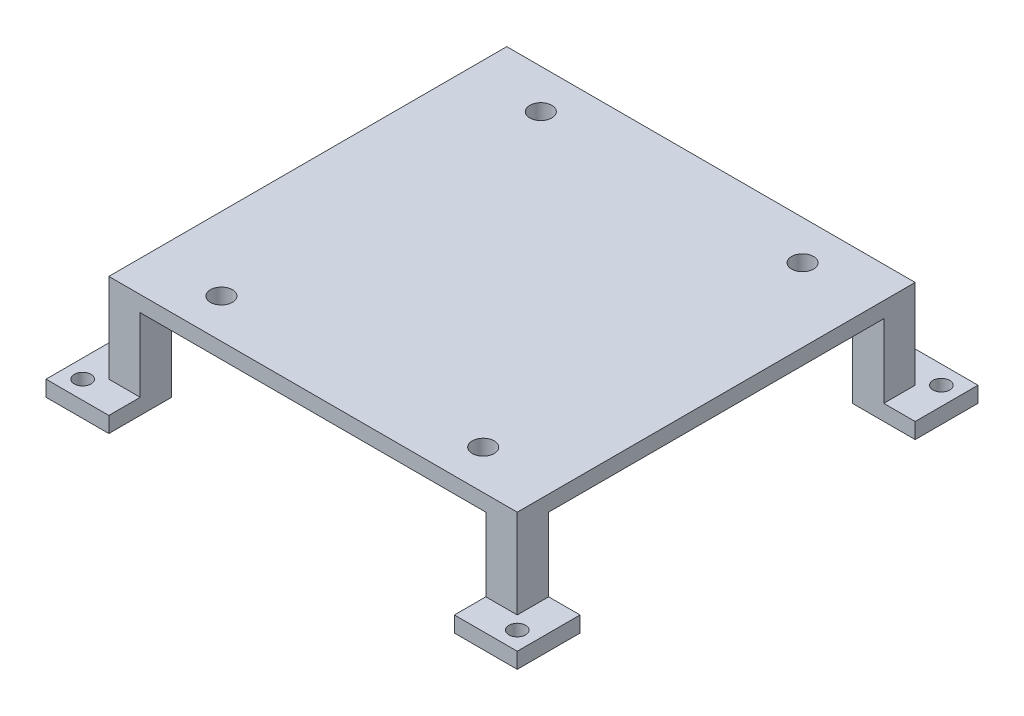
from build123d import *

# Parameters (mm, degrees)
SKETCH1_W             = 12
SKETCH1_H             = 12
BOSS_EXTRUDE1_DEPTH   = 3
BOSS_EXTRUDE1_2_DEPTH = 3
BOSS_EXTRUDE1_3_DEPTH = 3
BOSS_EXTRUDE1_4_DEPTH = 3
SKETCH2_W             = 6
SKETCH2_H             = 6
BOSS_EXTRUDE3_DEPTH   = 14
SKETCH3_W             = 78
SKETCH3_H             = 76
BOSS_EXTRUDE4_DEPTH   = 3
CUT_EXTRUDE1_REACH    = 5
SKETCH4_R             = 1.6
CUT_EXTRUDE2_REACH    = 22
SKETCH5_R             = 2.1


with BuildPart() as part:
    # Sketch1 → Boss-Extrude1 (new body)
    with BuildSketch(Plane(origin=(0, 0, 0), x_dir=(1, 0, 0), z_dir=(0, 1, 0))):
        with Locations((-39, -38)):
            Rectangle(SKETCH1_W, SKETCH1_H)
    extrude(amount=BOSS_EXTRUDE1_DEPTH)



with BuildPart() as body_2:
    # Sketch1 → Boss-Extrude1 2 (new body)
    with BuildSketch(Plane(origin=(0, 0, 0), x_dir=(1, 0, 0), z_dir=(0, 1, 0))):
        with Locations((-39, 38)):
            Rectangle(SKETCH1_W, SKETCH1_H)
    extrude(amount=BOSS_EXTRUDE1_2_DEPTH)


with BuildPart() as body_3:
    # Sketch1 → Boss-Extrude1 3 (new body)
    with BuildSketch(Plane(origin=(0, 0, 0), x_dir=(1, 0, 0), z_dir=(0, 1, 0))):
        with Locations((39, 38)):
            Rectangle(SKETCH1_W, SKETCH1_H)
    extrude(amount=BOSS_EXTRUDE1_3_DEPTH)


with BuildPart() as body_4:
    # Sketch1 → Boss-Extrude1 4 (new body)
    with BuildSketch(Plane(origin=(0, 0, 0), x_dir=(1, 0, 0), z_dir=(0, 1, 0))):
        with Locations((39, -38)):
            Rectangle(SKETCH1_W, SKETCH1_H)
    extrude(amount=BOSS_EXTRUDE1_4_DEPTH)


with BuildPart() as part_1:
    add(part.part)

    add(body_2.part)  # Boss-Extrude3 merges body 2

    add(body_3.part)  # Boss-Extrude3 merges body 3

    add(body_4.part)  # Boss-Extrude3 merges body 4
    # Sketch2 → Boss-Extrude3 (add)
    with BuildSketch(Plane(origin=(0, 3, 0), x_dir=(1, 0, 0), z_dir=(0, 1, 0))):
        with Locations((-36, 35)):
            Rectangle(SKETCH2_W, SKETCH2_H)
        with Locations((-36, -35)):
            Rectangle(SKETCH2_W, SKETCH2_H)
        with Locations((36, 35)):
            Rectangle(SKETCH2_W, SKETCH2_H)
        with Locations((36, -35)):
            Rectangle(SKETCH2_W, SKETCH2_H)
    extrude(amount=BOSS_EXTRUDE3_DEPTH)

    # Sketch3 → Boss-Extrude4 (add)
    with BuildSketch(Plane(origin=(0, 17, 0), x_dir=(1, 0, 0), z_dir=(0, 1, 0))):
        Rectangle(SKETCH3_W, SKETCH3_H)
    extrude(amount=BOSS_EXTRUDE4_DEPTH)

    # Sketch4 → Cut-Extrude1 (cut, up to next)
    with BuildSketch(Plane(origin=(0, 3, 0), x_dir=(1, 0, 0), z_dir=(0, 1, 0)), mode=Mode.PRIVATE) as cut_extrude1_sk1:
        with Locations((41.5, -40.5)):
            Circle(SKETCH4_R)
    cut_extrude1_tool1 = extrude(cut_extrude1_sk1.sketch, amount=-CUT_EXTRUDE1_REACH, mode=Mode.PRIVATE) & part_1.part
    add(cut_extrude1_tool1.solids().sort_by_distance((41.5, 3, 40.5))[0], mode=Mode.SUBTRACT)
    # Sketch4 → Cut-Extrude1 (cut, up to next)
    with BuildSketch(Plane(origin=(0, 3, 0), x_dir=(1, 0, 0), z_dir=(0, 1, 0)), mode=Mode.PRIVATE) as cut_extrude1_sk2:
        with Locations((-41.5, 40.5)):
            Circle(SKETCH4_R)
    cut_extrude1_tool2 = extrude(cut_extrude1_sk2.sketch, amount=-CUT_EXTRUDE1_REACH, mode=Mode.PRIVATE) & part_1.part
    add(cut_extrude1_tool2.solids().sort_by_distance((-41.5, 3, -40.5))[0], mode=Mode.SUBTRACT)
    # Sketch4 → Cut-Extrude1 (cut, up to next)
    with BuildSketch(Plane(origin=(0, 3, 0), x_dir=(1, 0, 0), z_dir=(0, 1, 0)), mode=Mode.PRIVATE) as cut_extrude1_sk3:
        with Locations((-41.5, -40.5)):
            Circle(SKETCH4_R)
    cut_extrude1_tool3 = extrude(cut_extrude1_sk3.sketch, amount=-CUT_EXTRUDE1_REACH, mode=Mode.PRIVATE) & part_1.part
    add(cut_extrude1_tool3.solids().sort_by_distance((-41.5, 3, 40.5))[0], mode=Mode.SUBTRACT)
    # Sketch4 → Cut-Extrude1 (cut, up to next)
    with BuildSketch(Plane(origin=(0, 3, 0), x_dir=(1, 0, 0), z_dir=(0, 1, 0)), mode=Mode.PRIVATE) as cut_extrude1_sk4:
        with Locations((41.5, 40.5)):
            Circle(SKETCH4_R)
    cut_extrude1_tool4 = extrude(cut_extrude1_sk4.sketch, amount=-CUT_EXTRUDE1_REACH, mode=Mode.PRIVATE) & part_1.part
    add(cut_extrude1_tool4.solids().sort_by_distance((41.5, 3, -40.5))[0], mode=Mode.SUBTRACT)

    # Sketch5 → Cut-Extrude2 (cut, up to next)
    with BuildSketch(Plane(origin=(0, 20, 0), x_dir=(1, 0, 0), z_dir=(0, 1, 0)), mode=Mode.PRIVATE) as cut_extrude2_sk1:
        with Locations((25, 30.5)):
            Circle(SKETCH5_R)
    cut_extrude2_tool1 = extrude(cut_extrude2_sk1.sketch, amount=-CUT_EXTRUDE2_REACH, mode=Mode.PRIVATE) & part_1.part
    add(cut_extrude2_tool1.solids().sort_by_distance((25, 20, -30.5))[0], mode=Mode.SUBTRACT)
    # Sketch5 → Cut-Extrude2 (cut, up to next)
    with BuildSketch(Plane(origin=(0, 20, 0), x_dir=(1, 0, 0), z_dir=(0, 1, 0)), mode=Mode.PRIVATE) as cut_extrude2_sk2:
        with Locations((25, -30.5)):
            Circle(SKETCH5_R)
    cut_extrude2_tool2 = extrude(cut_extrude2_sk2.sketch, amount=-CUT_EXTRUDE2_REACH, mode=Mode.PRIVATE) & part_1.part
    add(cut_extrude2_tool2.solids().sort_by_distance((25, 20, 30.5))[0], mode=Mode.SUBTRACT)
    # Sketch5 → Cut-Extrude2 (cut, up to next)
    with BuildSketch(Plane(origin=(0, 20, 0), x_dir=(1, 0, 0), z_dir=(0, 1, 0)), mode=Mode.PRIVATE) as cut_extrude2_sk3:
        with Locations((-25, 30.5)):
            Circle(SKETCH5_R)
    cut_extrude2_tool3 = extrude(cut_extrude2_sk3.sketch, amount=-CUT_EXTRUDE2_REACH, mode=Mode.PRIVATE) & part_1.part
    add(cut_extrude2_tool3.solids().sort_by_distance((-25, 20, -30.5))[0], mode=Mode.SUBTRACT)
    # Sketch5 → Cut-Extrude2 (cut, up to next)
    with BuildSketch(Plane(origin=(0, 20, 0), x_dir=(1, 0, 0), z_dir=(0, 1, 0)), mode=Mode.PRIVATE) as cut_extrude2_sk4:
        with Locations((-25, -30.5)):
            Circle(SKETCH5_R)
    cut_extrude2_tool4 = extrude(cut_extrude2_sk4.sketch, amount=-CUT_EXTRUDE2_REACH, mode=Mode.PRIVATE) & part_1.part
    add(cut_extrude2_tool4.solids().sort_by_distance((-25, 20, 30.5))[0], mode=Mode.SUBTRACT)


solid = part_1.part
